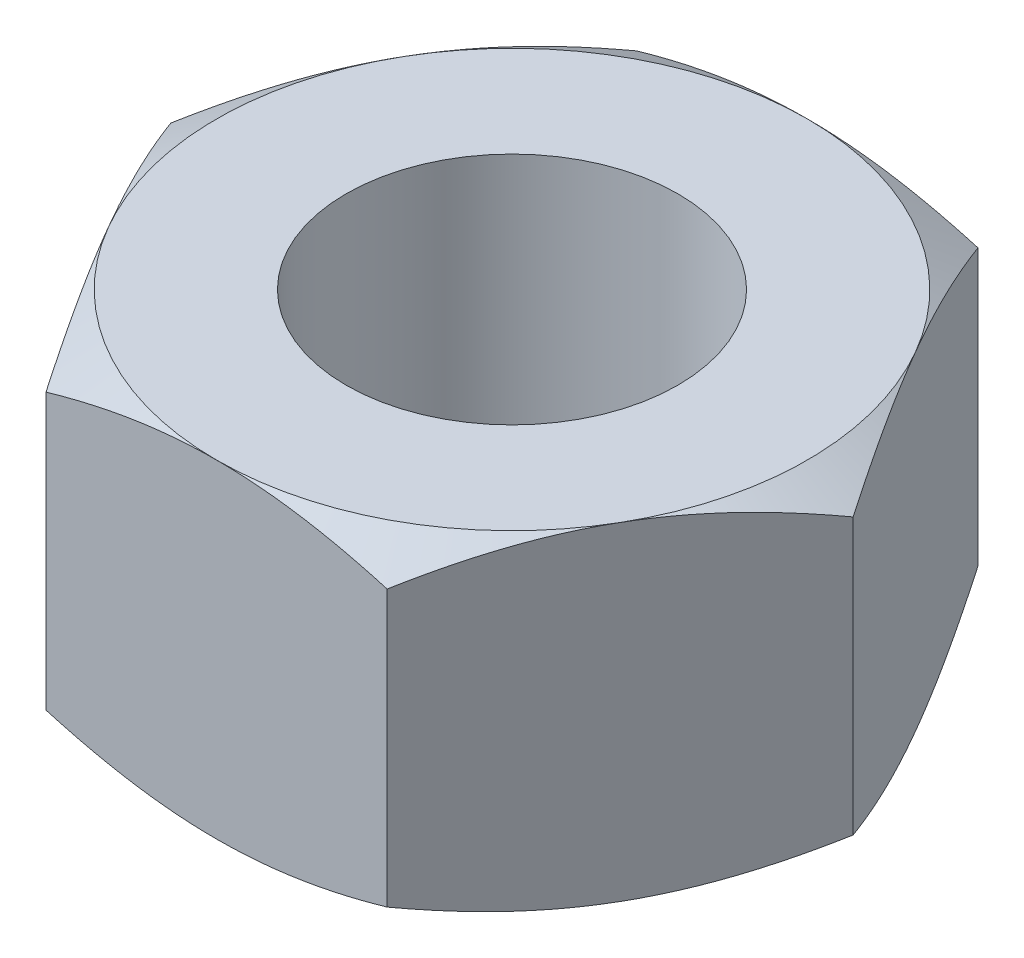
from build123d import *

# Parameters (mm, degrees)
SKETCH1_R           = 5.053
BOSS_EXTRUDE1_DEPTH = 10


with BuildPart() as part:
    # Sketch1 → Boss-Extrude1 (new body)
    with BuildSketch(Plane(origin=(0, 0, 0), x_dir=(1, 0, 0), z_dir=(0, 1, 0))):
        Polygon((5.196152423, 9), (-5.196152423, 9), (-10.392304845, 0), (-5.196152423, -9), (5.196152423, -9), (10.392304845, 0), align=None)
        Circle(SKETCH1_R, mode=Mode.SUBTRACT)
    extrude(amount=BOSS_EXTRUDE1_DEPTH)

    # Sketch2 → Cut-Revolve1 (revolve, cut)
    with BuildSketch(Plane.XY):
        Polygon((-10.392304845, 0.803847577), (-10.392304845, 0), (-9, 0), align=None)
        Polygon((-10.392304845, 10), (-10.392304845, 9.196152423), (-9, 10), align=None)
    revolve(axis=Axis((0, 55, 0), (0, -1, 0)), mode=Mode.SUBTRACT)


solid = part.part
